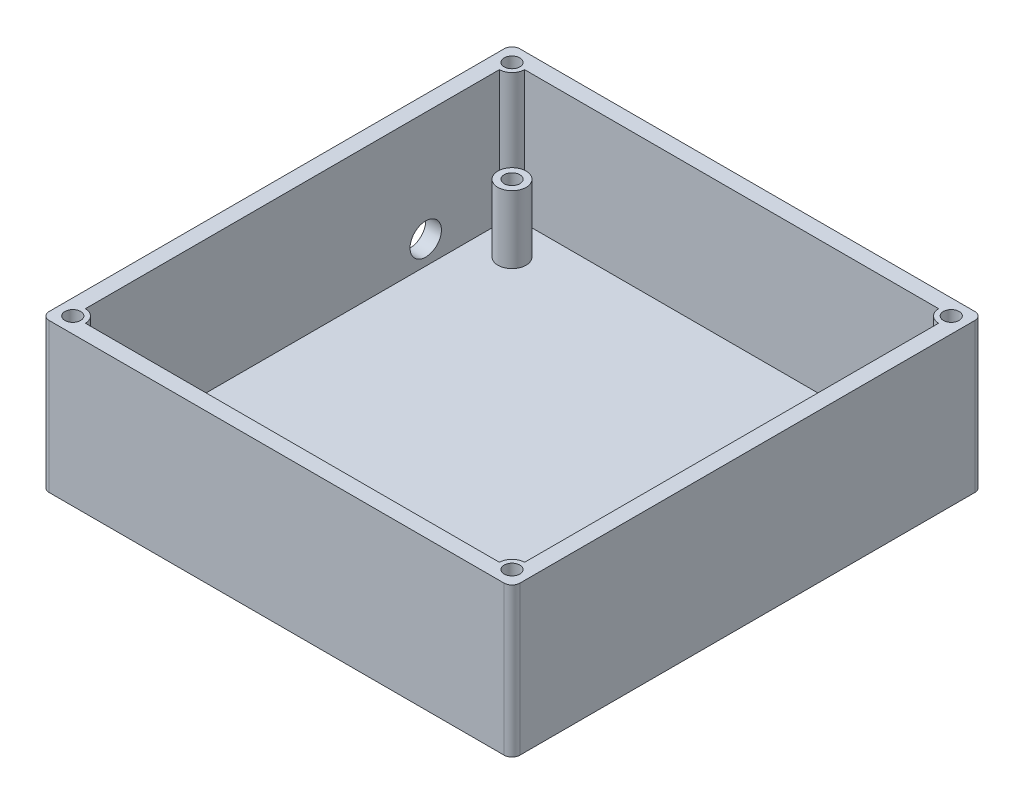
from build123d import *

# Parameters (mm, degrees)
SKETCH_1_W          = 56
SKETCH_1_H          = 56
EXTRUDE_1_DEPTH     = 2
SKETCH_2_R          = 1.8
EXTRUDE_2_DEPTH     = 8.6
SKETCH_3_R          = 1
CUT_EXTRUDE_1_DEPTH = 8.6
SKETCH_5_W          = 58
SKETCH_5_H          = 2
EXTRUDE_3_DEPTH     = 19
SKETCH_6_W          = 2
SKETCH_6_H          = 58
EXTRUDE_4_DEPTH     = 19
SKETCH_7_W          = 58
SKETCH_7_H          = 2
EXTRUDE_5_DEPTH     = 19
SKETCH_8_W          = 2
SKETCH_8_H          = 58
EXTRUDE_6_DEPTH     = 19
SKETCH_9_R          = 2
CUT_EXTRUDE_2_DEPTH = 2
SKETCH_10_R         = 1.6
EXTRUDE_7_DEPTH     = 17
SKETCH_11_R         = 1
CUT_EXTRUDE_3_DEPTH = 9
FILLET_1_R          = 1


with BuildPart() as part:
    # Эскиз1 → Бобышка-Вытянуть1 (new body)
    with BuildSketch(Plane(origin=(0, 0, 0), x_dir=(1, 0, 0), z_dir=(0, 1, 0))):
        Rectangle(SKETCH_1_W, SKETCH_1_H)
    extrude(amount=EXTRUDE_1_DEPTH)

    # Эскиз2 → Бобышка-Вытянуть2 (add)
    with BuildSketch(Plane(origin=(0, 2, 0), x_dir=(1, 0, 0), z_dir=(0, 1, 0))):
        with Locations((-23.5, -23.5)):
            Circle(SKETCH_2_R)
        with Locations((-23.5, 23.5)):
            Circle(SKETCH_2_R)
        with Locations((23.5, 23.5)):
            Circle(SKETCH_2_R)
        with Locations((23.5, -23.5)):
            Circle(SKETCH_2_R)
    extrude(amount=EXTRUDE_2_DEPTH)

    # Эскиз3 → Вырез-Вытянуть1 (cut)
    with BuildSketch(Plane(origin=(0, 10.6, 0), x_dir=(1, 0, 0), z_dir=(0, 1, 0))):
        with Locations((-23.5, 23.5)):
            Circle(SKETCH_3_R)
        with Locations((23.5, 23.4724717)):
            Circle(SKETCH_3_R)
        with Locations((23.5, -23.5)):
            Circle(SKETCH_3_R)
        with Locations((-23.5, -23.516051304)):
            Circle(SKETCH_3_R)
    extrude(amount=-CUT_EXTRUDE_1_DEPTH, mode=Mode.SUBTRACT)



with BuildPart() as body_2:
    # Эскиз5 → Бобышка-Вытянуть3 (new body)
    with BuildSketch(Plane.XZ):
        with Locations((1, -29)):
            Rectangle(SKETCH_5_W, SKETCH_5_H)
    extrude(amount=-EXTRUDE_3_DEPTH)


with BuildPart() as part_1:
    add(part.part)

    add(body_2.part)  # Бобышка-Вытянуть4 merges body 2
    # Эскиз6 → Бобышка-Вытянуть4 (add)
    with BuildSketch(Plane.XZ):
        with Locations((29, 1)):
            Rectangle(SKETCH_6_W, SKETCH_6_H)
    extrude(amount=-EXTRUDE_4_DEPTH)



with BuildPart() as body_2_2:
    # Эскиз7 → Бобышка-Вытянуть5 (new body)
    with BuildSketch(Plane.XZ):
        with Locations((-1, 29)):
            Rectangle(SKETCH_7_W, SKETCH_7_H)
    extrude(amount=-EXTRUDE_5_DEPTH)


with BuildPart() as part_2:
    add(part_1.part)

    add(body_2_2.part)  # Бобышка-Вытянуть6 merges body 2 2
    # Эскиз8 → Бобышка-Вытянуть6 (add)
    with BuildSketch(Plane.XZ):
        with Locations((-29, -1)):
            Rectangle(SKETCH_8_W, SKETCH_8_H)
    extrude(amount=-EXTRUDE_6_DEPTH)

    # Эскиз9 → Вырез-Вытянуть2 (cut)
    with BuildSketch(Plane.ZY.offset(30)):
        with Locations((-17, 5)):
            Circle(SKETCH_9_R)
    extrude(amount=-CUT_EXTRUDE_2_DEPTH, mode=Mode.SUBTRACT)

    # Эскиз10 → Бобышка-Вытянуть7 (add)
    with BuildSketch(Plane(origin=(0, 2, 0), x_dir=(1, 0, 0), z_dir=(0, 1, 0))):
        with Locations((-28, 28)):
            Circle(SKETCH_10_R)
        with Locations((28, 28)):
            Circle(SKETCH_10_R)
        with Locations((28, -28)):
            Circle(SKETCH_10_R)
        with Locations((-28, -28)):
            Circle(SKETCH_10_R)
    extrude(amount=EXTRUDE_7_DEPTH)

    # Эскиз11 → Вырез-Вытянуть3 (cut)
    with BuildSketch(Plane(origin=(0, 19, 0), x_dir=(1, 0, 0), z_dir=(0, 1, 0))):
        with Locations((-28, 28)):
            Circle(SKETCH_11_R)
        with Locations((28, 28)):
            Circle(SKETCH_11_R)
        with Locations((-28, -28)):
            Circle(SKETCH_11_R)
        with Locations((28, -28)):
            Circle(SKETCH_11_R)
    extrude(amount=-CUT_EXTRUDE_3_DEPTH, mode=Mode.SUBTRACT)

    # Скругление1
    fillet_1_edges = [part_2.edges().sort_by_distance(p)[0] for p in [
        (-30, 9.5, 30),
        (30, 9.5, 30),
        (30, 9.5, -30),
        (-30, 9.5, -30),
    ]]
    fillet(fillet_1_edges, radius=FILLET_1_R)


solid = part_2.part
